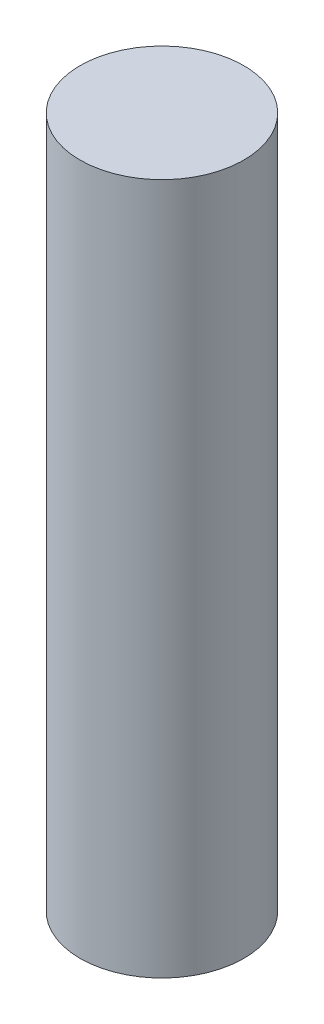
from build123d import *

# Parameters (mm, degrees)
SKETCH1_R           = 25.5651
BOSS_EXTRUDE1_DEPTH = 215.9


with BuildPart() as part:
    # Sketch1 → Boss-Extrude1 (new body)
    with BuildSketch(Plane(origin=(0, 0, 0), x_dir=(1, 0, 0), z_dir=(0, 1, 0))):
        Circle(SKETCH1_R)
    extrude(amount=BOSS_EXTRUDE1_DEPTH)


solid = part.part
